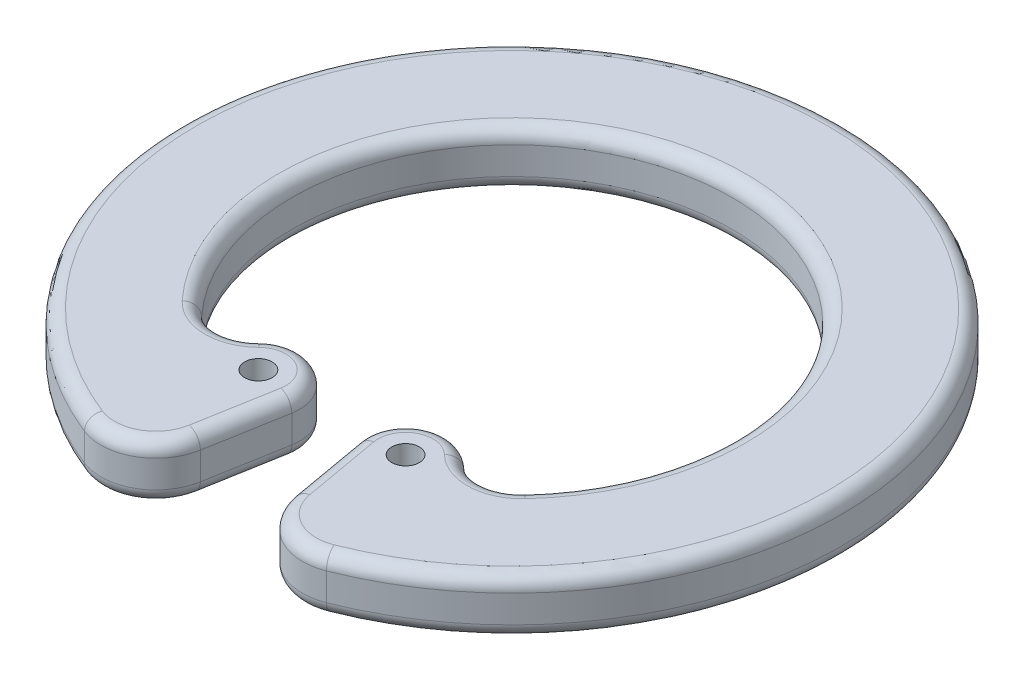
from build123d import *

# Parameters (mm, degrees)
SKETCH1_R           = 0.5
BOSS_EXTRUDE1_DEPTH = 1
FILLET1_R           = 0.5


with BuildPart() as part:
    # Sketch1 → Boss-Extrude1 (new body, symmetric)
    with BuildSketch(Plane(origin=(0, 0, 0), x_dir=(1, 0, 0), z_dir=(0, 1, 0))):
        with BuildLine():
            Line((1.70139772, -9.649105958), (1.202143228, -6.817693036))
            ThreePointArc((1.202143228, -6.817693036), (1.978682409, -5.230925886), (3.727083265, -5.483784612))
            ThreePointArc((3.727083265, -5.483784612), (4.813640695, -5.909845806), (5.876691289, -5.428121175))
            ThreePointArc((5.876691289, -5.428121175), (0, 8), (-5.876691289, -5.428121175))
            ThreePointArc((-5.876691289, -5.428121175), (-4.813640695, -5.909845806), (-3.727083265, -5.483784612))
            ThreePointArc((-3.727083265, -5.483784612), (-1.978682409, -5.230925886), (-1.202143228, -6.817693036))
            Line((-1.202143228, -6.817693036), (-1.70139772, -9.649105958))
            ThreePointArc((-1.70139772, -9.649105958), (-2.694333604, -11.047116715), (-4.405215871, -11.162171524))
            ThreePointArc((-4.405215871, -11.162171524), (0, 12), (4.405215871, -11.162171524))
            ThreePointArc((4.405215871, -11.162171524), (2.694333604, -11.047116715), (1.70139772, -9.649105958))
        make_face()
        with Locations((2.679354858, -6.55722077)):
            Circle(SKETCH1_R, mode=Mode.SUBTRACT)
        with Locations((-2.679354858, -6.55722077)):
            Circle(SKETCH1_R, mode=Mode.SUBTRACT)
    extrude(amount=BOSS_EXTRUDE1_DEPTH, both=True)

    # Fillet1
    fillet1_edges = [part.edges().sort_by_distance(p)[0] for p in [
        (1.451770474, -1, 8.233399497),
        (1.978682409, -1, 5.230925886),
        (4.813640695, -1, 5.909845806),
        (0, -1, -8),
        (-4.813640695, -1, 5.909845806),
        (-1.978682409, -1, 5.230925886),
        (-1.451770474, -1, 8.233399497),
        (-2.694333604, 1, 11.047116715),
        (-2.694333604, -1, 11.047116715),
        (0, -1, -12),
        (2.694333604, -1, 11.047116715),
        (-1.451770474, 1, 8.233399497),
        (-1.978682409, 1, 5.230925886),
        (-4.813640695, 1, 5.909845806),
        (0, 1, -8),
        (4.813640695, 1, 5.909845806),
        (1.978682409, 1, 5.230925886),
        (1.451770474, 1, 8.233399497),
        (2.694333604, 1, 11.047116715),
        (0, 1, -12),
    ]]
    fillet(fillet1_edges, radius=FILLET1_R)


solid = part.part
